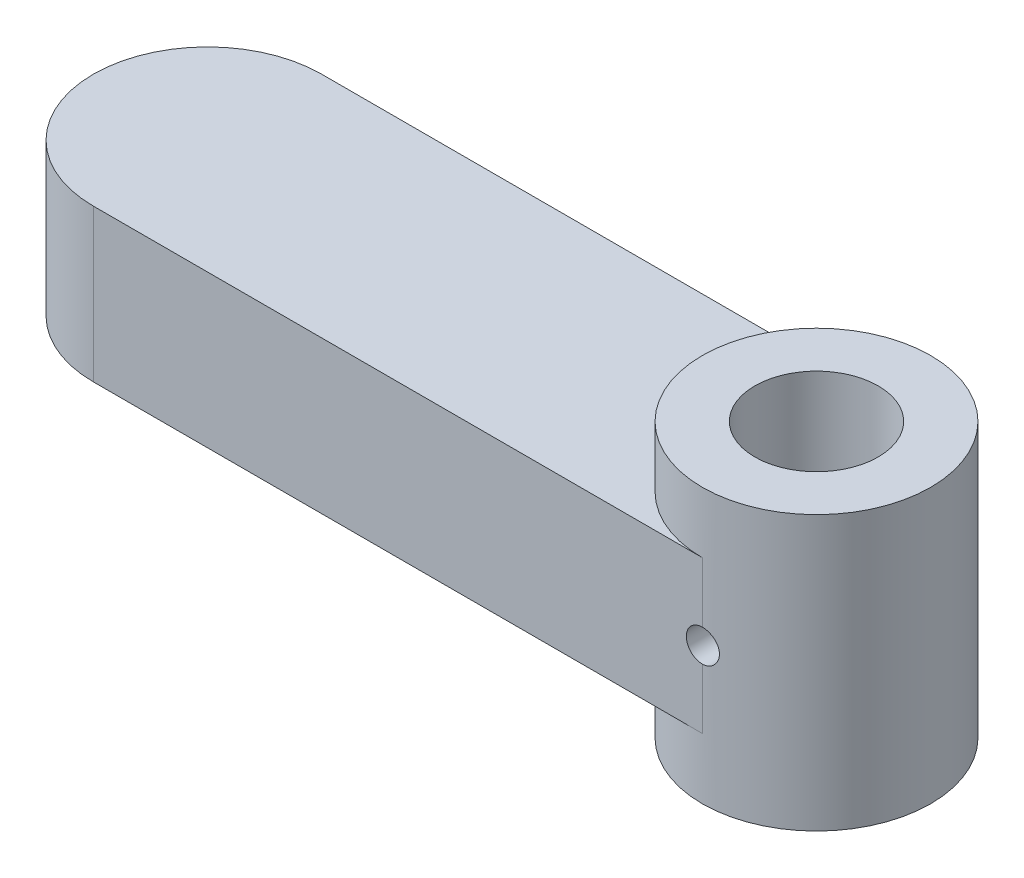
from build123d import *

# Parameters (mm, degrees)
SKETCH1_R           = 4.05
BOSS_EXTRUDE1_DEPTH = 10
SKETCH2_R           = 1.05
CUT_EXTRUDE1_DEPTH  = 16
CUT_EXTRUDE2_DEPTH  = 2
SKETCH4_R           = 4.05
BOSS_EXTRUDE2_DEPTH = 4
BOSS_EXTRUDE3_START = -10
SKETCH4_4_R         = 7.5
SKETCH4_4_R_2       = 4.05
BOSS_EXTRUDE3_DEPTH = 4


with BuildPart() as part:
    # Sketch1 → Boss-Extrude1 (new body)
    with BuildSketch(Plane(origin=(0, 0, 0), x_dir=(1, 0, 0), z_dir=(0, 1, 0))):
        with BuildLine():
            Line((0, 7.5), (-40, 7.5))
            ThreePointArc((-40, 7.5), (-47.5, 0), (-40, -7.5))
            Line((-40, -7.5), (0, -7.5))
            ThreePointArc((0, -7.5), (7.5, 0), (0, 7.5))
        make_face()
        Circle(SKETCH1_R, mode=Mode.SUBTRACT)
    extrude(amount=BOSS_EXTRUDE1_DEPTH)

    # Sketch2 → Cut-Extrude1 (cut, through all)
    with BuildSketch(Plane(origin=(0, 0, -7.5), x_dir=(-1, 0, 0), z_dir=(0, 0, -1))):
        with Locations((0, 5)):
            Circle(SKETCH2_R)
    extrude(amount=-CUT_EXTRUDE1_DEPTH, mode=Mode.SUBTRACT)

    # Sketch3 → Cut-Extrude2 (cut)
    with BuildSketch(Plane(origin=(0, 0, -7.5), x_dir=(-1, 0, 0), z_dir=(0, 0, -1))):
        Polygon((40.929088354, 3.218244664), (40.570113995, 3.218244664), (40.570113995, 4.741481843), (38.902646047, 3.218244664), (38.390626816, 3.218244664), (40.356171688, 5.013116459), (38.236780662, 7.218244664), (38.715146047, 7.218244664), (40.570113995, 5.287956202), (40.570113995, 7.218244664), (40.929088354, 7.218244664), align=None)
        with BuildLine():
            Line((37.647037072, 3.218244664), (36.846556303, 3.218244664))
            add(Edge.make_bspline(
                [(36.846556303, 3.218244664), (36.744007128, 3.218828499), (36.597004555, 3.218503013), (36.410111246, 3.226123479), (36.290086835, 3.230812809), (36.183566657, 3.23940462), (36.067956369, 3.249421931), (35.988416855, 3.261967393), (35.940306303, 3.272731843)],
                knots=[0, 0, 0, 0, 0.338434414, 0.484822051, 0.617157578, 0.734698361, 0.837385184, 1, 1, 1, 1], degree=3))
            add(Edge.make_bspline(
                [(35.940306303, 3.272731843), (35.882035492, 3.285520817), (35.797337898, 3.312250277), (35.690304974, 3.359492647), (35.615010559, 3.400827648), (35.543929022, 3.447915711), (35.477056011, 3.500898242), (35.415291244, 3.560242001), (35.356436344, 3.623485337), (35.305044975, 3.693382717), (35.25877851, 3.766386792), (35.219941567, 3.843903112), (35.189373116, 3.925540787), (35.163777825, 4.010498614), (35.140331502, 4.131147592), (35.133924488, 4.224698895), (35.13421656, 4.287956202)],
                knots=[0, 0, 0, 0, 0.12703991, 0.188709102, 0.249085329, 0.309868062, 0.370230871, 0.430628561, 0.492276732, 0.55409549, 0.615218447, 0.676314893, 0.738476023, 0.800795937, 0.865209823, 1, 1, 1, 1], degree=3))
            add(Edge.make_bspline(
                [(35.13421656, 4.287956202), (35.133851273, 4.391753147), (35.151529211, 4.545837461), (35.219797958, 4.736970222), (35.288677316, 4.867426437), (35.376459169, 4.985082333), (35.481925789, 5.088072659), (35.604568346, 5.175052979), (35.719274916, 5.234729101), (35.820649118, 5.273127225), (35.904351589, 5.300280122), (35.995726172, 5.320904514), (36.093461991, 5.339652818), (36.198313768, 5.353944974), (36.351848987, 5.367969268), (36.470962495, 5.371851723), (36.55248579, 5.372090818)],
                knots=[0, 0, 0, 0, 0.153710705, 0.226698871, 0.29917182, 0.371165996, 0.44297777, 0.516334013, 0.592857108, 0.63351018, 0.676623617, 0.722915422, 0.771971354, 0.823829257, 0.87938645, 1, 1, 1, 1], degree=3))
            Line((36.55248579, 5.372090818), (35.082934508, 7.218244664))
            Line((35.082934508, 7.218244664), (35.526844765, 7.218244664))
            Line((35.526844765, 7.218244664), (36.996396047, 5.372090818))
            Line((36.996396047, 5.372090818), (37.288062713, 5.372090818))
            Line((37.288062713, 5.372090818), (37.288062713, 7.218244664))
            Line((37.288062713, 7.218244664), (37.647037072, 7.218244664))
            Line((37.647037072, 7.218244664), (37.647037072, 3.218244664))
        make_face()
        with BuildLine():
            Line((37.288062713, 3.628501074), (37.288062713, 4.961834408))
            Line((37.288062713, 4.961834408), (36.555690919, 4.967443382))
            add(Edge.make_bspline(
                [(36.555690919, 4.967443382), (36.489395839, 4.96850809), (36.39346407, 4.964990732), (36.270051699, 4.95771806), (36.187719806, 4.949791186), (36.112296464, 4.939556152), (36.043831075, 4.926739346), (35.982172459, 4.911869116), (35.910489388, 4.888618754), (35.829523645, 4.85337095), (35.743344779, 4.798716252), (35.667989878, 4.732619308), (35.605318407, 4.656083076), (35.555061588, 4.571569514), (35.507787437, 4.449923256), (35.492551158, 4.352592843), (35.493190919, 4.28715492)],
                knots=[0, 0, 0, 0, 0.138878011, 0.201133482, 0.259058627, 0.312175748, 0.360589919, 0.404983277, 0.444988631, 0.518418117, 0.589382616, 0.65799459, 0.727585942, 0.795840798, 0.863196901, 1, 1, 1, 1], degree=3))
            add(Edge.make_bspline(
                [(35.493190919, 4.28715492), (35.493147755, 4.223479249), (35.507115599, 4.127898701), (35.556395922, 4.009542208), (35.606516869, 3.92678534), (35.668986461, 3.8522182), (35.741726909, 3.788612845), (35.823051617, 3.735771196), (35.898443594, 3.700906167), (35.966323218, 3.680391549), (36.024987828, 3.665499924), (36.091851756, 3.655070878), (36.16612804, 3.645477235), (36.248142827, 3.637360126), (36.372880198, 3.629835176), (36.470472566, 3.628266136), (36.538062713, 3.628501074)],
                knots=[0, 0, 0, 0, 0.136311338, 0.203719134, 0.273224715, 0.34260796, 0.411061944, 0.479238515, 0.549585203, 0.587913733, 0.630891961, 0.67900679, 0.732608365, 0.791193356, 0.855339952, 1, 1, 1, 1], degree=3))
            Line((36.538062713, 3.628501074), (37.288062713, 3.628501074))
        make_face(mode=Mode.SUBTRACT)
        Polygon((29.441908867, 7.218244664), (29.441908867, 3.218244664), (29.366588354, 3.218244664), (26.723960149, 6.366481843), (26.723960149, 3.218244664), (26.36498579, 3.218244664), (26.36498579, 7.218244664), (26.44671656, 7.218244664), (29.082934508, 4.077219023), (29.082934508, 7.218244664), align=None)
        Polygon((25.339344765, 3.218244664), (24.980370406, 3.218244664), (24.980370406, 4.741481843), (23.312902457, 3.218244664), (22.800883226, 3.218244664), (24.766428098, 5.013116459), (22.647037072, 7.218244664), (23.125402457, 7.218244664), (24.980370406, 5.287956202), (24.980370406, 7.218244664), (25.339344765, 7.218244664), align=None)
        with BuildLine():
            Line((22.467549893, 6.446610049), (22.129408867, 6.24388569))
            add(Edge.make_bspline(
                [(22.129408867, 6.24388569), (22.070854246, 6.345536569), (21.97838095, 6.488088264), (21.833014713, 6.649517295), (21.724481812, 6.744275123), (21.612170923, 6.818742537), (21.457891257, 6.888961018), (21.333487426, 6.910768902), (21.251203739, 6.910552356)],
                knots=[0, 0, 0, 0, 0.3046461, 0.438546905, 0.562322299, 0.677432543, 0.786897393, 1, 1, 1, 1], degree=3))
            add(Edge.make_bspline(
                [(21.251203739, 6.910552356), (21.18174501, 6.910832383), (21.077700593, 6.899629798), (20.945004966, 6.859347231), (20.850358444, 6.818853608), (20.762651292, 6.769009332), (20.68451805, 6.710246849), (20.618506099, 6.642359639), (20.563913101, 6.567800621), (20.521244721, 6.488123663), (20.48049632, 6.377828076), (20.467505339, 6.290653647), (20.467549893, 6.232667741)],
                knots=[0, 0, 0, 0, 0.181010038, 0.27040523, 0.360512832, 0.448738091, 0.532675464, 0.614375665, 0.694558805, 0.772713677, 0.849122955, 1, 1, 1, 1], degree=3))
            add(Edge.make_bspline(
                [(20.467549893, 6.232667741), (20.466850812, 6.165045717), (20.495235685, 6.024052899), (20.566846817, 5.899691655), (20.61097938, 5.840039536)],
                knots=[0, 0, 0, 0, 0.475390581, 1, 1, 1, 1], degree=3))
            add(Edge.make_bspline(
                [(20.61097938, 5.840039536), (20.6474132, 5.790756475), (20.71137583, 5.718541477), (20.806618851, 5.623203085), (20.892077297, 5.545652546), (20.9872634, 5.463901277), (21.133653958, 5.34701292), (21.250262859, 5.260042894), (21.332133226, 5.202219023)],
                knots=[0, 0, 0, 0, 0.190099402, 0.299186879, 0.418361668, 0.548359268, 0.688774766, 1, 1, 1, 1], degree=3))
            add(Edge.make_bspline(
                [(21.332133226, 5.202219023), (21.412990598, 5.145471323), (21.526507571, 5.061700951), (21.667805377, 4.95175731), (21.756836452, 4.88146861), (21.831995076, 4.815957528), (21.910875385, 4.745735278), (21.959955787, 4.692231325), (21.987581944, 4.65814851)],
                knots=[0, 0, 0, 0, 0.347075306, 0.495558726, 0.629076644, 0.745524338, 0.845833579, 1, 1, 1, 1], degree=3))
            add(Edge.make_bspline(
                [(21.987581944, 4.65814851), (22.022906348, 4.612340094), (22.072342712, 4.542093062), (22.124714584, 4.442010533), (22.155916888, 4.366255068), (22.181102088, 4.289218086), (22.204644771, 4.183947577), (22.211404111, 4.103122451), (22.211139636, 4.049174151)],
                knots=[0, 0, 0, 0, 0.262550464, 0.388251856, 0.511530984, 0.633734148, 0.755401792, 1, 1, 1, 1], degree=3))
            add(Edge.make_bspline(
                [(22.211139636, 4.049174151), (22.211442855, 3.965418411), (22.195362177, 3.841061732), (22.142527499, 3.683745093), (22.086052942, 3.574428263), (22.016197069, 3.473046023), (21.933303654, 3.381395001), (21.835792157, 3.302635201), (21.727237691, 3.235667737), (21.609807676, 3.182300248), (21.443914486, 3.129749362), (21.312966811, 3.116572305), (21.225562713, 3.115680561)],
                knots=[0, 0, 0, 0, 0.165770437, 0.246265968, 0.327681675, 0.408711214, 0.489624888, 0.571614731, 0.656207004, 0.741698291, 0.826556649, 1, 1, 1, 1], degree=3))
            add(Edge.make_bspline(
                [(21.225562713, 3.115680561), (21.132017966, 3.114909237), (20.992066805, 3.133804612), (20.814070287, 3.193982983), (20.707276332, 3.247196514), (20.623664362, 3.299857074), (20.559967973, 3.34793179), (20.495069914, 3.403162078), (20.42966464, 3.466710521), (20.363125546, 3.537319694), (20.27048417, 3.644745228), (20.203393683, 3.731388042), (20.159857585, 3.792763895)],
                knots=[0, 0, 0, 0, 0.212612572, 0.318547415, 0.426488723, 0.483329676, 0.543275454, 0.607966231, 0.677191883, 0.750735922, 0.828747966, 1, 1, 1, 1], degree=3))
            Line((20.159857585, 3.792763895), (20.484376816, 4.038757485))
            add(Edge.make_bspline(
                [(20.484376816, 4.038757485), (20.521541513, 3.989677297), (20.57803654, 3.920958295), (20.652955159, 3.834582201), (20.706491006, 3.78064294), (20.755521167, 3.730997776), (20.803950967, 3.689246818), (20.849912597, 3.654069757), (20.907714527, 3.61647221), (20.981121691, 3.580145232), (21.103634678, 3.537947688), (21.200885444, 3.526119193), (21.265626816, 3.525936972)],
                knots=[0, 0, 0, 0, 0.189595982, 0.274136202, 0.352121651, 0.423699703, 0.489040362, 0.548952296, 0.601909863, 0.701279607, 0.80043443, 1, 1, 1, 1], degree=3))
            add(Edge.make_bspline(
                [(21.265626816, 3.525936972), (21.345283257, 3.524455618), (21.461572489, 3.542401356), (21.601746465, 3.604192687), (21.689366663, 3.668671902), (21.761613001, 3.745642585), (21.832854581, 3.863070773), (21.851999852, 3.965051237), (21.852165278, 4.032347228)],
                knots=[0, 0, 0, 0, 0.275822022, 0.401868693, 0.527874505, 0.650458955, 0.765963766, 1, 1, 1, 1], degree=3))
            add(Edge.make_bspline(
                [(21.852165278, 4.032347228), (21.852977956, 4.075534259), (21.844744637, 4.139903684), (21.820945624, 4.223359122), (21.795786024, 4.285828936), (21.761519275, 4.349680436), (21.695748685, 4.441540051), (21.633662789, 4.505864343), (21.588543483, 4.549174151)],
                knots=[0, 0, 0, 0, 0.216119916, 0.32340733, 0.434613213, 0.55329871, 0.68599313, 1, 1, 1, 1], degree=3))
            add(Edge.make_bspline(
                [(21.588543483, 4.549174151), (21.56798575, 4.568013995), (21.530391774, 4.598960997), (21.470725904, 4.643420459), (21.409639907, 4.689821554), (21.336527369, 4.743620384), (21.215370452, 4.829831513), (21.119329114, 4.899271346), (21.050883226, 4.947411331)],
                knots=[0, 0, 0, 0, 0.124951974, 0.218093899, 0.333502411, 0.468789179, 0.624937586, 1, 1, 1, 1], degree=3))
            add(Edge.make_bspline(
                [(21.050883226, 4.947411331), (20.966713383, 5.008387801), (20.84513776, 5.097790294), (20.695352317, 5.22196148), (20.597673462, 5.309243565), (20.509830802, 5.393287997), (20.432705052, 5.475035855), (20.365953941, 5.553952445), (20.293087985, 5.654439519), (20.219652335, 5.779002018), (20.136601189, 5.978589167), (20.108552759, 6.135310825), (20.108575534, 6.238276715)],
                knots=[0, 0, 0, 0, 0.187763162, 0.272381231, 0.35130177, 0.424311551, 0.491881862, 0.554202887, 0.610843189, 0.715917624, 0.814550236, 1, 1, 1, 1], degree=3))
            add(Edge.make_bspline(
                [(20.108575534, 6.238276715), (20.107483556, 6.309368846), (20.119039319, 6.414643535), (20.153054673, 6.550717962), (20.190433394, 6.647671249), (20.23723722, 6.741398663), (20.294199468, 6.831738084), (20.363237019, 6.917204517), (20.439927944, 6.999457997), (20.525112574, 7.073847873), (20.615255218, 7.140106698), (20.709849957, 7.196835616), (20.80997738, 7.241415336), (20.913986763, 7.277029396), (21.060413083, 7.311748355), (21.174445705, 7.321122074), (21.251203739, 7.320808767)],
                knots=[0, 0, 0, 0, 0.121779146, 0.180926421, 0.240265226, 0.299715473, 0.360502633, 0.423143728, 0.487999854, 0.553287074, 0.616916643, 0.679808819, 0.742177612, 0.804655804, 0.868253993, 1, 1, 1, 1], degree=3))
            add(Edge.make_bspline(
                [(21.251203739, 7.320808767), (21.311277656, 7.321067872), (21.400232614, 7.314123925), (21.516965396, 7.294019679), (21.601190433, 7.2713852), (21.683745228, 7.243233119), (21.763895357, 7.208776676), (21.841833873, 7.167754043), (21.917657148, 7.120105113), (21.992059088, 7.065176837), (22.064739699, 7.001756528), (22.136061707, 6.930147139), (22.206325824, 6.850450526), (22.273858998, 6.761340503), (22.365061007, 6.628352879), (22.427272275, 6.521060101), (22.467549893, 6.446610049)],
                knots=[0, 0, 0, 0, 0.113700276, 0.168685943, 0.22415832, 0.278721005, 0.333797387, 0.389246684, 0.445400209, 0.503284563, 0.564257591, 0.627941476, 0.694625909, 0.765364026, 0.839605496, 1, 1, 1, 1], degree=3))
        make_face()
        Polygon((17.749601175, 3.218244664), (17.390626816, 3.218244664), (17.390626816, 6.807988254), (15.852165278, 6.807988254), (15.852165278, 7.218244664), (17.749601175, 7.218244664), align=None)
        Polygon((15.185498611, 3.218244664), (12.929088354, 3.218244664), (12.929088354, 3.628501074), (14.826524252, 3.628501074), (14.826524252, 4.859270305), (12.929088354, 4.859270305), (12.929088354, 5.269526715), (14.826524252, 5.269526715), (14.826524252, 6.807988254), (12.929088354, 6.807988254), (12.929088354, 7.218244664), (15.185498611, 7.218244664), align=None)
        Polygon((12.518831944, 3.218244664), (12.13421656, 3.218244664), (10.800883226, 6.370488254), (9.467549893, 3.218244664), (9.082934508, 3.218244664), (10.775242201, 7.218244664), (10.826524252, 7.218244664), align=None)
        Polygon((8.313703739, 3.218244664), (6.057293483, 3.218244664), (6.057293483, 3.628501074), (7.95472938, 3.628501074), (7.95472938, 4.859270305), (6.057293483, 4.859270305), (6.057293483, 5.269526715), (7.95472938, 5.269526715), (7.95472938, 6.807988254), (6.057293483, 6.807988254), (6.057293483, 7.218244664), (8.313703739, 7.218244664), align=None)
        with BuildLine():
            Line((5.339344765, 3.218244664), (4.538863995, 3.218244664))
            add(Edge.make_bspline(
                [(4.538863995, 3.218244664), (4.43631482, 3.218828499), (4.289312247, 3.218503013), (4.102418938, 3.226123479), (3.982394527, 3.230812809), (3.875874349, 3.23940462), (3.760264062, 3.249421931), (3.680724547, 3.261967393), (3.632613995, 3.272731843)],
                knots=[0, 0, 0, 0, 0.338434414, 0.484822051, 0.617157578, 0.734698361, 0.837385184, 1, 1, 1, 1], degree=3))
            add(Edge.make_bspline(
                [(3.632613995, 3.272731843), (3.574343184, 3.285520817), (3.48964559, 3.312250277), (3.382612667, 3.359492647), (3.307318251, 3.400827648), (3.236236714, 3.447915711), (3.169363703, 3.500898242), (3.107598936, 3.560242001), (3.048744037, 3.623485337), (2.997352668, 3.693382717), (2.951086203, 3.766386792), (2.912249259, 3.843903112), (2.881680808, 3.925540787), (2.856085517, 4.010498614), (2.832639195, 4.131147592), (2.82623218, 4.224698895), (2.826524252, 4.287956202)],
                knots=[0, 0, 0, 0, 0.12703991, 0.188709102, 0.249085329, 0.309868062, 0.370230871, 0.430628561, 0.492276732, 0.55409549, 0.615218447, 0.676314893, 0.738476023, 0.800795937, 0.865209823, 1, 1, 1, 1], degree=3))
            add(Edge.make_bspline(
                [(2.826524252, 4.287956202), (2.826158966, 4.391753147), (2.843836903, 4.545837461), (2.91210565, 4.736970222), (2.980985009, 4.867426437), (3.068766861, 4.985082333), (3.174233481, 5.088072659), (3.296876038, 5.175052979), (3.411582608, 5.234729101), (3.512956811, 5.273127225), (3.596659281, 5.300280122), (3.688033864, 5.320904514), (3.785769683, 5.339652818), (3.89062146, 5.353944974), (4.04415668, 5.367969268), (4.163270188, 5.371851723), (4.244793483, 5.372090818)],
                knots=[0, 0, 0, 0, 0.153710705, 0.226698871, 0.29917182, 0.371165996, 0.44297777, 0.516334013, 0.592857108, 0.63351018, 0.676623617, 0.722915422, 0.771971354, 0.823829257, 0.87938645, 1, 1, 1, 1], degree=3))
            Line((4.244793483, 5.372090818), (2.775242201, 7.218244664))
            Line((2.775242201, 7.218244664), (3.219152457, 7.218244664))
            Line((3.219152457, 7.218244664), (4.688703739, 5.372090818))
            Line((4.688703739, 5.372090818), (4.980370406, 5.372090818))
            Line((4.980370406, 5.372090818), (4.980370406, 7.218244664))
            Line((4.980370406, 7.218244664), (5.339344765, 7.218244664))
            Line((5.339344765, 7.218244664), (5.339344765, 3.218244664))
        make_face()
        with BuildLine():
            Line((4.980370406, 3.628501074), (4.980370406, 4.961834408))
            Line((4.980370406, 4.961834408), (4.247998611, 4.967443382))
            add(Edge.make_bspline(
                [(4.247998611, 4.967443382), (4.181703531, 4.96850809), (4.085771762, 4.964990732), (3.962359392, 4.95771806), (3.880027498, 4.949791186), (3.804604156, 4.939556152), (3.736138768, 4.926739346), (3.674480151, 4.911869116), (3.60279708, 4.888618754), (3.521831337, 4.85337095), (3.435652472, 4.798716252), (3.360297571, 4.732619308), (3.297626099, 4.656083076), (3.247369281, 4.571569514), (3.200095129, 4.449923256), (3.18485885, 4.352592843), (3.185498611, 4.28715492)],
                knots=[0, 0, 0, 0, 0.138878011, 0.201133482, 0.259058627, 0.312175748, 0.360589919, 0.404983277, 0.444988631, 0.518418117, 0.589382616, 0.65799459, 0.727585942, 0.795840798, 0.863196901, 1, 1, 1, 1], degree=3))
            add(Edge.make_bspline(
                [(3.185498611, 4.28715492), (3.185455447, 4.223479249), (3.199423291, 4.127898701), (3.248703614, 4.009542208), (3.298824561, 3.92678534), (3.361294153, 3.8522182), (3.434034601, 3.788612845), (3.51535931, 3.735771196), (3.590751286, 3.700906167), (3.65863091, 3.680391549), (3.71729552, 3.665499924), (3.784159448, 3.655070878), (3.858435732, 3.645477235), (3.940450519, 3.637360126), (4.065187891, 3.629835176), (4.162780258, 3.628266136), (4.230370406, 3.628501074)],
                knots=[0, 0, 0, 0, 0.136311338, 0.203719134, 0.273224715, 0.34260796, 0.411061944, 0.479238515, 0.549585203, 0.587913733, 0.630891961, 0.67900679, 0.732608365, 0.791193356, 0.855339952, 1, 1, 1, 1], degree=3))
            Line((4.230370406, 3.628501074), (4.980370406, 3.628501074))
        make_face(mode=Mode.SUBTRACT)
        with BuildLine():
            add(Edge.make_bspline(
                [(32.390626816, 3.115680561), (32.245244831, 3.11610498), (32.029710218, 3.132866651), (31.752883197, 3.196989861), (31.557279164, 3.263507271), (31.371381576, 3.349851113), (31.194605973, 3.454650344), (31.027559154, 3.578961182), (30.870673238, 3.719825651), (30.728079595, 3.874665581), (30.603998234, 4.040897043), (30.4983999, 4.215174373), (30.412098582, 4.398632594), (30.344374467, 4.590452241), (30.280825354, 4.862455383), (30.262136774, 5.07376665), (30.262421688, 5.2166421)],
                knots=[0, 0, 0, 0, 0.13073763, 0.193341164, 0.25498957, 0.316108392, 0.377251257, 0.43938486, 0.502966344, 0.566515184, 0.628263548, 0.689117745, 0.749366545, 0.810186161, 0.871621029, 1, 1, 1, 1], degree=3))
            add(Edge.make_bspline(
                [(30.262421688, 5.2166421), (30.262150001, 5.358440354), (30.280816306, 5.568473709), (30.344583021, 5.838673099), (30.411259777, 6.030213403), (30.497624771, 6.2133019), (30.603389229, 6.387701148), (30.727191835, 6.554417324), (30.869200834, 6.710011014), (31.024276352, 6.852617838), (31.189480825, 6.978686077), (31.364614813, 7.083702175), (31.546945809, 7.171291835), (31.738284873, 7.23754877), (32.007271736, 7.303218963), (32.217140554, 7.320737664), (32.358575534, 7.320808767)],
                knots=[0, 0, 0, 0, 0.128576319, 0.190331218, 0.251392307, 0.312186107, 0.37359078, 0.436091904, 0.500231152, 0.564354845, 0.626953074, 0.688357747, 0.749255231, 0.810087631, 0.871663616, 1, 1, 1, 1], degree=3))
            add(Edge.make_bspline(
                [(32.358575534, 7.320808767), (32.50144591, 7.321108826), (32.713032078, 7.302353045), (32.985170567, 7.238787451), (33.177730804, 7.171947349), (33.361447482, 7.085775348), (33.536302317, 6.979912049), (33.702505518, 6.855159014), (33.858365918, 6.713261539), (34.000800724, 6.558483373), (34.126082276, 6.393495866), (34.231334909, 6.219867937), (34.317544276, 6.038315492), (34.385639549, 5.849307296), (34.448815419, 5.582585618), (34.467993341, 5.375594943), (34.467549893, 5.235872869)],
                knots=[0, 0, 0, 0, 0.129754547, 0.192083828, 0.253475092, 0.314589033, 0.376095281, 0.438844932, 0.503090279, 0.567320043, 0.629681905, 0.690980548, 0.751436286, 0.811992743, 0.87314184, 1, 1, 1, 1], degree=3))
            add(Edge.make_bspline(
                [(34.467549893, 5.235872869), (34.468609457, 5.141269518), (34.458506689, 5.000343778), (34.429879779, 4.81514406), (34.399409568, 4.679677941), (34.360033392, 4.546898306), (34.311527461, 4.417075295), (34.25593495, 4.289139924), (34.189745697, 4.165526928), (34.11753091, 4.046042317), (34.038788029, 3.932180137), (33.952967918, 3.825974277), (33.861296523, 3.725718178), (33.762504901, 3.633122986), (33.658079864, 3.546169906), (33.547475012, 3.46575907), (33.430515423, 3.393579222), (33.310183017, 3.327281466), (33.18560481, 3.271927171), (33.059409155, 3.22300558), (32.930484922, 3.184112194), (32.799128664, 3.153217361), (32.619492754, 3.124784891), (32.482576729, 3.114587352), (32.390626816, 3.115680561)],
                knots=[0, 0, 0, 0, 0.085881169, 0.128132386, 0.170168405, 0.211938097, 0.253861187, 0.296020311, 0.338574299, 0.381150423, 0.422820599, 0.464244847, 0.505120974, 0.546150251, 0.587164454, 0.62852183, 0.670271074, 0.711969505, 0.753242069, 0.794029495, 0.834869589, 0.875486283, 0.916539236, 1, 1, 1, 1], degree=3))
        make_face()
        with BuildLine():
            add(Edge.make_bspline(
                [(32.372998611, 3.525936972), (32.448603879, 3.524876871), (32.561327951, 3.533487035), (32.709711904, 3.556696005), (32.81891216, 3.581683644), (32.926528289, 3.613764103), (33.032681336, 3.653362326), (33.137465667, 3.69959486), (33.239923199, 3.753259275), (33.338417613, 3.813411821), (33.433540734, 3.876832499), (33.521659691, 3.947116001), (33.604476531, 4.021655936), (33.68179033, 4.101478623), (33.753611423, 4.185996038), (33.819869026, 4.275590813), (33.879769031, 4.369889646), (33.933074929, 4.468367286), (33.980802961, 4.569140894), (34.020364073, 4.673395012), (34.051715786, 4.780478459), (34.078275138, 4.889921533), (34.100946331, 5.041190009), (34.109801304, 5.156507858), (34.108575534, 5.234270305)],
                knots=[0, 0, 0, 0, 0.083634277, 0.124967906, 0.166226326, 0.207589577, 0.24923634, 0.291611976, 0.334345341, 0.377209532, 0.419377167, 0.46085975, 0.501906639, 0.542695883, 0.583825813, 0.624645074, 0.666000921, 0.707429689, 0.748581948, 0.789397994, 0.830761245, 0.872086406, 0.914004329, 1, 1, 1, 1], degree=3))
            add(Edge.make_bspline(
                [(34.108575534, 5.234270305), (34.108943735, 5.347950341), (34.093107829, 5.516134648), (34.040257661, 5.732620474), (33.98394145, 5.885606331), (33.912001071, 6.03198418), (33.824273635, 6.171184411), (33.71992833, 6.303165913), (33.601472738, 6.42694637), (33.471944188, 6.539880278), (33.334469977, 6.639151372), (33.190137612, 6.722694934), (33.039778977, 6.792556719), (32.882110506, 6.845109542), (32.660759169, 6.896089198), (32.489022286, 6.911519455), (32.372998611, 6.910552356)],
                knots=[0, 0, 0, 0, 0.1268942, 0.187738963, 0.248419712, 0.308585774, 0.369580252, 0.4318217, 0.49617186, 0.56065739, 0.623491454, 0.685244918, 0.746642893, 0.808335087, 0.870491415, 1, 1, 1, 1], degree=3))
            add(Edge.make_bspline(
                [(32.372998611, 6.910552356), (32.294555318, 6.910891092), (32.177440733, 6.904128519), (32.023732016, 6.88066394), (31.911448182, 6.855539789), (31.801319002, 6.824470098), (31.693681977, 6.785936882), (31.588553798, 6.739764085), (31.485489227, 6.688224231), (31.386720633, 6.630096732), (31.293369644, 6.566228913), (31.204822368, 6.498330818), (31.12215669, 6.424330696), (31.045165661, 6.345181353), (30.974628175, 6.260306357), (30.908401463, 6.171382758), (30.848921591, 6.077107893), (30.794884421, 5.979409476), (30.748558505, 5.878342492), (30.708974435, 5.774546978), (30.677058968, 5.667920829), (30.652081905, 5.558709667), (30.628715043, 5.408187857), (30.620377439, 5.293300813), (30.621396047, 5.215840818)],
                knots=[0, 0, 0, 0, 0.086551414, 0.129197693, 0.17146334, 0.213449527, 0.255404662, 0.297514824, 0.340092799, 0.382506193, 0.423874281, 0.464849866, 0.505557411, 0.546205151, 0.586586979, 0.627264633, 0.668477012, 0.709503453, 0.750388823, 0.791063273, 0.832000674, 0.873115963, 0.914597308, 1, 1, 1, 1], degree=3))
            add(Edge.make_bspline(
                [(30.621396047, 5.215840818), (30.620384224, 5.138915145), (30.628700235, 5.02481929), (30.652100769, 4.875376046), (30.676934203, 4.767188108), (30.709001611, 4.661932843), (30.748527313, 4.559707943), (30.795139789, 4.460132853), (30.848634769, 4.363453743), (30.908766962, 4.270682279), (30.974475504, 4.181995053), (31.046889879, 4.099050127), (31.123960046, 4.019827871), (31.207538926, 3.945912834), (31.297641174, 3.87759085), (31.3920231, 3.811782634), (31.492820087, 3.753544347), (31.596470035, 3.699481828), (31.702935455, 3.653395574), (31.810885122, 3.613588212), (31.920462773, 3.581821669), (32.031480762, 3.556671791), (32.182014711, 3.533503095), (32.296326596, 3.524869316), (32.372998611, 3.525936972)],
                knots=[0, 0, 0, 0, 0.085123374, 0.126463518, 0.167440062, 0.207960217, 0.248230142, 0.288727612, 0.329644311, 0.370508574, 0.411096706, 0.451783902, 0.492367721, 0.533444523, 0.575218486, 0.617559484, 0.66078721, 0.704052373, 0.746976364, 0.789184872, 0.831405817, 0.873247812, 0.915172343, 1, 1, 1, 1], degree=3))
        make_face(mode=Mode.SUBTRACT)
    extrude(amount=-CUT_EXTRUDE2_DEPTH, mode=Mode.SUBTRACT)

    # Sketch4 → Boss-Extrude2 (add)
    with BuildSketch(Plane.XZ):
        with BuildLine():
            ThreePointArc((0, -7.5), (5.303300859, -5.303300859), (7.5, 0))
            ThreePointArc((7.5, 0), (5.303300859, 5.303300859), (0, 7.5))
            ThreePointArc((0, 7.5), (-7.5, 0), (0, -7.5))
        make_face()
        Circle(SKETCH4_R, mode=Mode.SUBTRACT)
    extrude(amount=BOSS_EXTRUDE2_DEPTH)

    # Sketch4_4 → Boss-Extrude3 (add)
    with BuildSketch(Plane.XZ.offset(BOSS_EXTRUDE3_START)):
        Circle(SKETCH4_4_R)
        Circle(SKETCH4_4_R_2, mode=Mode.SUBTRACT)
    extrude(amount=-BOSS_EXTRUDE3_DEPTH)


solid = part.part
